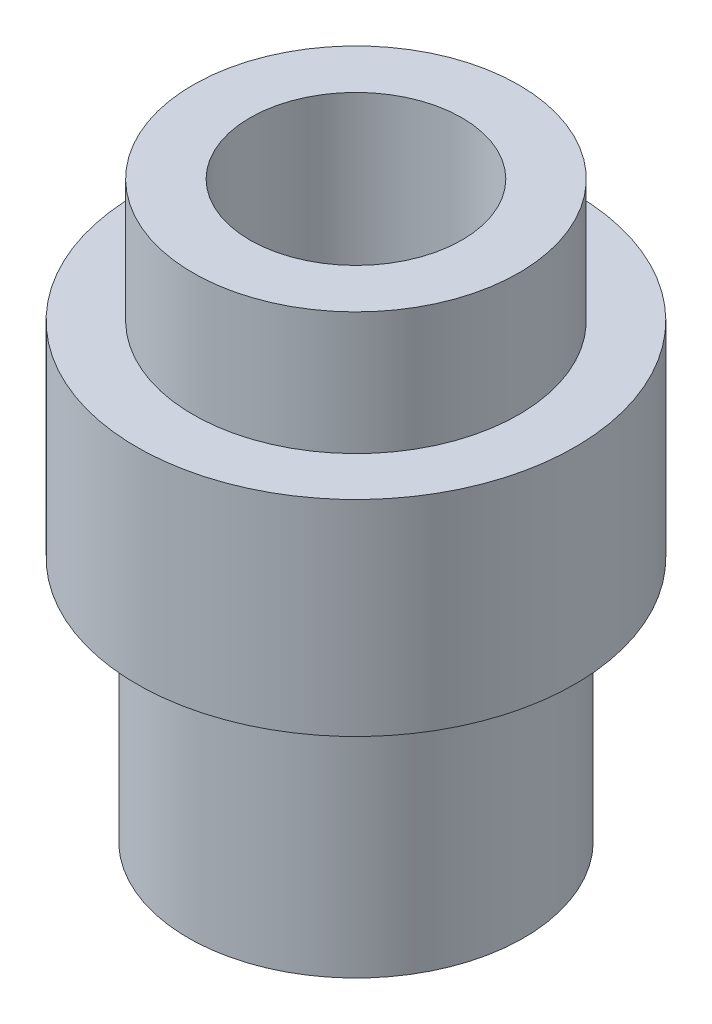
from build123d import *


with BuildPart() as part:
    # Sketch2 → Revolve1 (revolve)
    with BuildSketch(Plane.XY):
        Polygon((3.760145388, 0), (3.760145388, 5.5), (4.91, 5.5), (4.91, 10.1), (3.65, 10.1), (3.65, 12.85), (2.375, 12.85), (2.375, 3.42704397), (0, 2), (0, 0), align=None)
    revolve(axis=Axis((0, 0, 0), (0, 1, 0)))


solid = part.part
